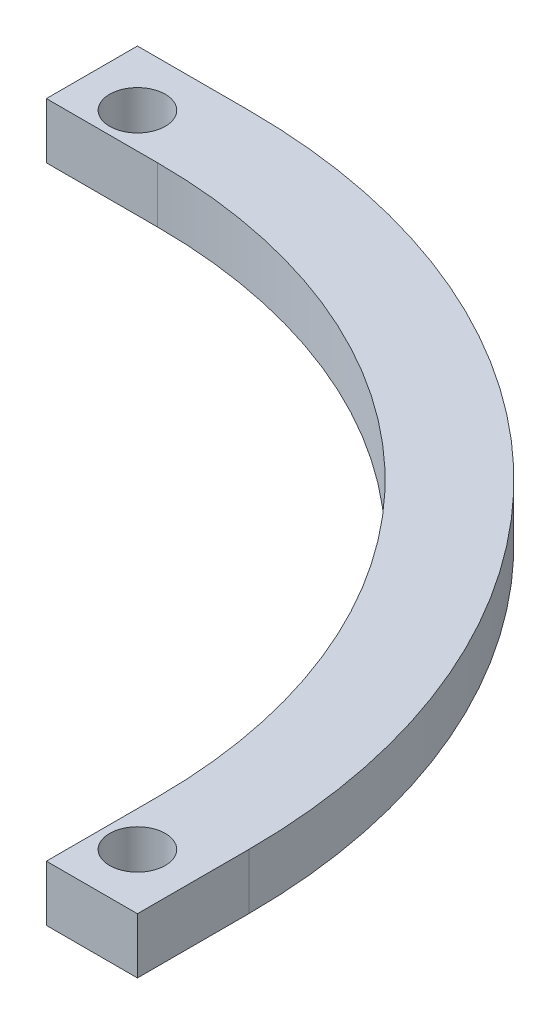
from build123d import *

# Parameters (mm, degrees)
SKETCH1_R              = 2.5
BOSS_EXTRUDE2_DEPTH    = 5
SPLIT1_SURFACE_1_BACK  = 96.59
SPLIT1_SURFACE_1_DEPTH = 193.18


with BuildPart() as part:
    # Sketch1 → Boss-Extrude2 (new body)
    with BuildSketch(Plane(origin=(0, 0, 0), x_dir=(1, 0, 0), z_dir=(0, 1, 0))):
        with BuildLine():
            Line((47.5, 0), (47.5, -10))
            Line((47.5, -10), (57.5, -10))
            Line((57.5, -10), (57.5, 0))
            ThreePointArc((57.5, 0), (40.658639918, 40.658639918), (0, 57.5))
            Line((0, 57.5), (-10, 57.5))
            Line((-10, 57.5), (-10, 47.5))
            Line((-10, 47.5), (0, 47.5))
            ThreePointArc((0, 47.5), (33.587572106, 33.587572106), (47.5, 0))
        make_face()
        with Locations(Location((52.5, -5, 0), (0, 0, 270))):
            Circle(SKETCH1_R, mode=Mode.SUBTRACT)
        with Locations(Location((-5, 52.5, 0), (0, 0, 90))):
            Circle(SKETCH1_R, mode=Mode.SUBTRACT)
    extrude(amount=BOSS_EXTRUDE2_DEPTH)

    # Split1: cut with a surface, the side behind it stays
    # Split1 surface: a surface, the sketch's curves swept straight by 193.18 mm
    with BuildLine(Plane(origin=(0, 5, 0), x_dir=(1, 0, 0), z_dir=(0, 1, 0)).offset(-SPLIT1_SURFACE_1_BACK), mode=Mode.PRIVATE) as split1_surface_1_path:
        Line((49.32, -10), (49.32, 0))
        ThreePointArc((49.32, 0), (34.874506448, 34.874506448), (0, 49.32))
        Line((0, 49.32), (-10, 49.32))
    split1_surface_1 = Shell.extrude(split1_surface_1_path.wire(), (0 * SPLIT1_SURFACE_1_DEPTH, 1 * SPLIT1_SURFACE_1_DEPTH, 0 * SPLIT1_SURFACE_1_DEPTH))
    split(bisect_by=split1_surface_1, keep=Keep.BOTTOM)


solid = part.part
